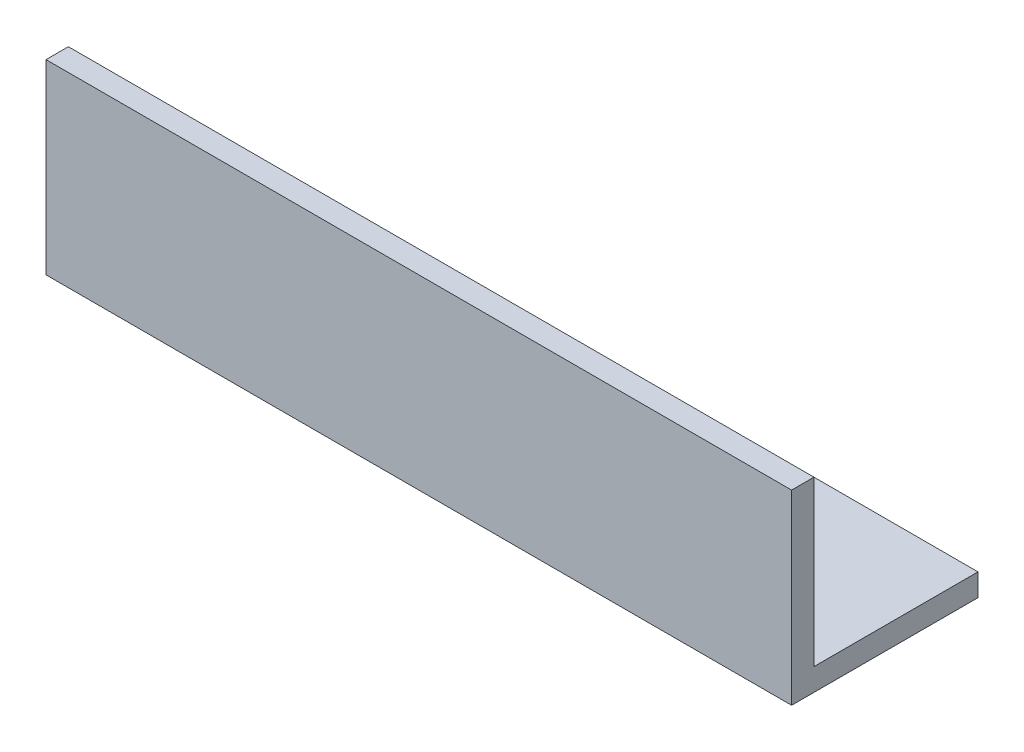
from build123d import *

# Parameters (mm, degrees)
EXTRUDE_1_DEPTH = 100


with BuildPart() as part:
    # Эскиз1 → Вытянуть-Тонкостенный1 (new body)
    with BuildSketch(Plane(origin=(0, 0, 0), x_dir=(0, 0, -1), z_dir=(1, 0, 0))):
        Polygon((0, 25), (0, 0), (25, 0), (25, 3), (3, 3), (3, 25), align=None)
    extrude(amount=EXTRUDE_1_DEPTH)


solid = part.part
